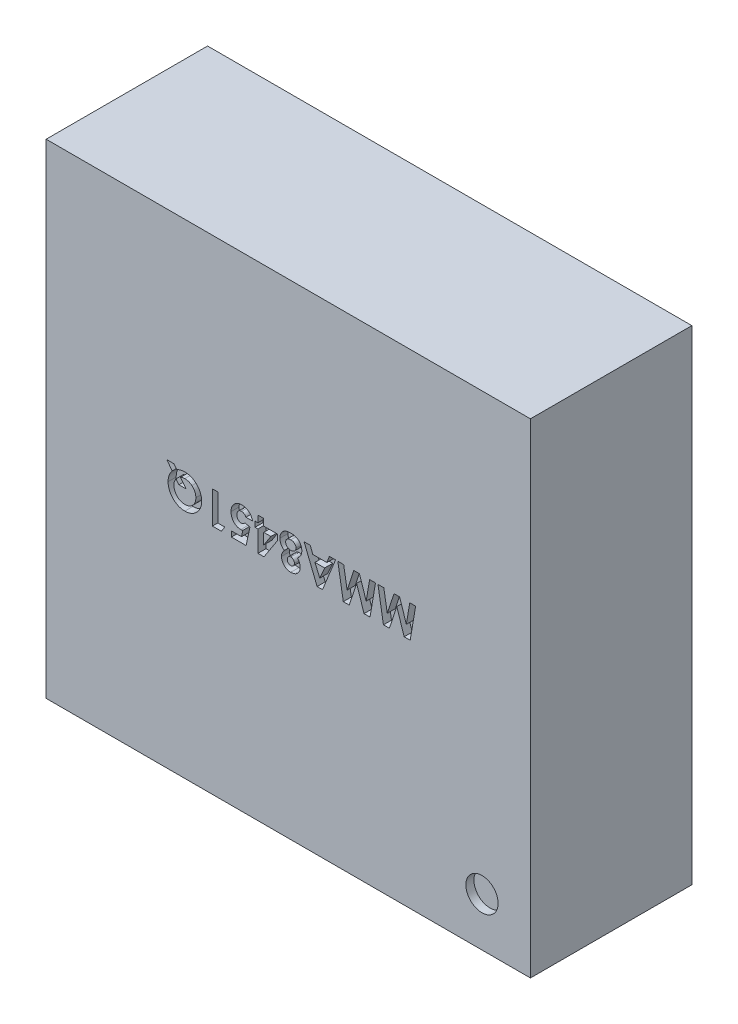
from build123d import *

# Parameters (mm, degrees)
SCHIZZO1_W                   = 3
SCHIZZO1_H                   = 3
ESTRUSIONE_ESTRUSIONE1_DEPTH = 1
TAGLIO_ESTRUSIONE1_DEPTH     = 0.05
SCHIZZO3_R                   = 0.1
TAGLIO_ESTRUSIONE2_DEPTH     = 0.05


with BuildPart() as part:
    # Schizzo1 → Estrusione-Estrusione1 (new body)
    with BuildSketch(Plane.XY):
        with Locations((1.5, 1.5)):
            Rectangle(SCHIZZO1_W, SCHIZZO1_H)
    extrude(amount=ESTRUSIONE_ESTRUSIONE1_DEPTH)

    # Schizzo2 → Taglio-Estrusione1 (cut)
    with BuildSketch(Plane.XY.offset(1)):
        Polygon((2.255120111, 1.439408505), (2.217860496, 1.439408505), (2.172227483, 1.57891171), (2.126273957, 1.439408505), (2.089374919, 1.439408505), (2.055560816, 1.639408505), (2.091898957, 1.639408505), (2.113253124, 1.51308639), (2.154839662, 1.639408505), (2.189855688, 1.639408505), (2.231201842, 1.51308639), (2.252515944, 1.639408505), (2.288894149, 1.639408505), align=None)
        Polygon((2.006402162, 1.439408505), (1.969142547, 1.439408505), (1.923509534, 1.57891171), (1.877556008, 1.439408505), (1.84065697, 1.439408505), (1.806842867, 1.639408505), (1.843181008, 1.639408505), (1.864535175, 1.51308639), (1.906121714, 1.639408505), (1.941137739, 1.639408505), (1.982483893, 1.51308639), (2.003797996, 1.639408505), (2.040176201, 1.639408505), align=None)
        Polygon((1.711931008, 1.439408505), (1.678637739, 1.439408505), (1.597868508, 1.639408505), (1.636209855, 1.639408505), (1.651754726, 1.598382864), (1.738894149, 1.598382864), (1.754439021, 1.639408505), (1.792740303, 1.639408505), align=None)
        Polygon((1.695304406, 1.493054338), (1.725272355, 1.562485428), (1.665336457, 1.562485428), align=None, mode=Mode.SUBTRACT)
        with BuildLine():
            add(Edge.make_bspline(
                [(1.475272355, 1.531716197), (1.473174734, 1.533214414), (1.469022685, 1.53618), (1.463553194, 1.541491573), (1.45881142, 1.547397544), (1.45486563, 1.553878723), (1.45171337, 1.560815484), (1.449547066, 1.568114497), (1.448098465, 1.575662829), (1.447945723, 1.580801283), (1.447868508, 1.58339889)],
                knots=[0, 0, 0, 0, 7.724e-06, 1.529e-05, 2.2786e-05, 3.0392e-05, 3.7995e-05, 4.5574e-05, 5.3189e-05, 6.0974e-05, 6.0974e-05, 6.0974e-05, 6.0974e-05], degree=3))
            add(Edge.make_bspline(
                [(1.447868508, 1.58339889), (1.447963328, 1.586211217), (1.448151391, 1.591789107), (1.449818242, 1.599968088), (1.452480363, 1.607818284), (1.456152804, 1.615246932), (1.460736074, 1.622049379), (1.466046988, 1.628119642), (1.472164822, 1.633189867), (1.477814874, 1.636679063), (1.482712005, 1.638942737), (1.48663211, 1.64048813), (1.490839032, 1.641706274), (1.495262585, 1.642754008), (1.499948926, 1.643539533), (1.504851919, 1.644157897), (1.51001753, 1.644457776), (1.513533286, 1.644509951), (1.515336457, 1.64453671)],
                knots=[0, 0, 0, 0, 8.43e-06, 1.6719e-05, 2.4929e-05, 3.3243e-05, 4.1499e-05, 4.9474e-05, 5.7353e-05, 6.5248e-05, 6.9317e-05, 7.3528e-05, 7.7876e-05, 8.2443e-05, 8.7159e-05, 9.2124e-05, 9.7262e-05, 0.000102672, 0.000102672, 0.000102672, 0.000102672], degree=3))
            add(Edge.make_bspline(
                [(1.515336457, 1.64453671), (1.517259849, 1.644510473), (1.521015855, 1.644459236), (1.52649937, 1.644153208), (1.531669796, 1.643578114), (1.536550559, 1.642854562), (1.541096901, 1.641780111), (1.545369218, 1.640612022), (1.549321298, 1.63916093), (1.554152226, 1.636922846), (1.559751981, 1.633575715), (1.565728375, 1.628571639), (1.571053363, 1.622704405), (1.575513142, 1.615931994), (1.579229331, 1.608542297), (1.581881464, 1.600572463), (1.583478894, 1.592130125), (1.583669122, 1.586343939), (1.583765944, 1.58339889)],
                knots=[0, 0, 0, 0, 5.77e-06, 1.1269e-05, 1.6467e-05, 2.1374e-05, 2.6059e-05, 3.0473e-05, 3.4655e-05, 3.8671e-05, 4.6435e-05, 5.4145e-05, 6.1974e-05, 7.0119e-05, 7.8397e-05, 8.672e-05, 9.5238e-05, 0.000104068, 0.000104068, 0.000104068, 0.000104068], degree=3))
            add(Edge.make_bspline(
                [(1.583765944, 1.58339889), (1.583699882, 1.580828655), (1.583569986, 1.57577486), (1.582218931, 1.568398584), (1.580159054, 1.561343636), (1.577148533, 1.554674957), (1.573368853, 1.548311853), (1.568660948, 1.542384881), (1.56318548, 1.536748952), (1.559018628, 1.533421609), (1.556882931, 1.531716197)],
                knots=[0, 0, 0, 0, 7.703e-06, 1.5146e-05, 2.2422e-05, 2.9703e-05, 3.7034e-05, 4.4568e-05, 5.2359e-05, 6.0551e-05, 6.0551e-05, 6.0551e-05, 6.0551e-05], degree=3))
            add(Edge.make_bspline(
                [(1.556882931, 1.531716197), (1.558207018, 1.530189886), (1.560813745, 1.527185037), (1.564178132, 1.522344969), (1.567049191, 1.517364535), (1.569365917, 1.512214275), (1.571228576, 1.506953564), (1.572568417, 1.501550026), (1.57333037, 1.495987468), (1.573449408, 1.492228587), (1.573509534, 1.490329979)],
                knots=[0, 0, 0, 0, 6.058e-06, 1.1927e-05, 1.7651e-05, 2.3281e-05, 2.8844e-05, 3.4373e-05, 3.9954e-05, 4.565e-05, 4.565e-05, 4.565e-05, 4.565e-05], degree=3))
            add(Edge.make_bspline(
                [(1.573509534, 1.490329979), (1.573430438, 1.487759632), (1.573274386, 1.482688437), (1.571866729, 1.475265663), (1.569581685, 1.468187924), (1.566358072, 1.461548301), (1.562391141, 1.455409429), (1.557588715, 1.449982648), (1.552092392, 1.44524061), (1.545869846, 1.441281529), (1.539030809, 1.438153041), (1.531650405, 1.435904192), (1.523762687, 1.434508086), (1.51832046, 1.434357384), (1.515536778, 1.4342803)],
                knots=[0, 0, 0, 0, 7.705e-06, 1.5202e-05, 2.2575e-05, 2.9958e-05, 3.7281e-05, 4.4434e-05, 5.1622e-05, 5.899e-05, 6.6484e-05, 7.4113e-05, 8.2083e-05, 9.0428e-05, 9.0428e-05, 9.0428e-05, 9.0428e-05], degree=3))
            add(Edge.make_bspline(
                [(1.515536778, 1.4342803), (1.512793171, 1.434357286), (1.507443713, 1.434507392), (1.499682449, 1.435899564), (1.492438044, 1.43819607), (1.485720458, 1.441365902), (1.479584485, 1.445371003), (1.474185721, 1.45025658), (1.469402872, 1.45582552), (1.465390595, 1.46210962), (1.462161873, 1.468880232), (1.459803283, 1.475994075), (1.458420065, 1.48337197), (1.458223694, 1.488374552), (1.458124919, 1.490890877)],
                knots=[0, 0, 0, 0, 8.225e-06, 1.6037e-05, 2.3563e-05, 3.0965e-05, 3.8254e-05, 4.5461e-05, 5.2735e-05, 6.0215e-05, 6.7759e-05, 7.5183e-05, 8.2641e-05, 9.0188e-05, 9.0188e-05, 9.0188e-05, 9.0188e-05], degree=3))
            add(Edge.make_bspline(
                [(1.458124919, 1.490890877), (1.458172799, 1.492669127), (1.458266761, 1.496158809), (1.458958948, 1.50130085), (1.460131298, 1.506231724), (1.461743636, 1.511089958), (1.464078698, 1.51594002), (1.467063659, 1.521016113), (1.47085941, 1.526328266), (1.473755045, 1.529863657), (1.475272355, 1.531716197)],
                knots=[0, 0, 0, 0, 5.334e-06, 1.0467e-05, 1.553e-05, 2.0522e-05, 2.5791e-05, 3.1646e-05, 3.8171e-05, 4.5354e-05, 4.5354e-05, 4.5354e-05, 4.5354e-05], degree=3))
        make_face()
        with BuildLine():
            add(Edge.make_bspline(
                [(1.516418188, 1.470177736), (1.517895864, 1.47025031), (1.52078309, 1.470392112), (1.524883649, 1.471627748), (1.528576876, 1.473652577), (1.531764766, 1.476464288), (1.534354839, 1.479913015), (1.536291315, 1.483843989), (1.537428727, 1.488237035), (1.537549786, 1.491311546), (1.537612098, 1.492894082)],
                knots=[0, 0, 0, 0, 4.425e-06, 8.646e-06, 1.2717e-05, 1.6976e-05, 2.1295e-05, 2.5577e-05, 3.0047e-05, 3.4788e-05, 3.4788e-05, 3.4788e-05, 3.4788e-05], degree=3))
            add(Edge.make_bspline(
                [(1.537612098, 1.492894082), (1.53753441, 1.494489875), (1.537382716, 1.497605816), (1.536216072, 1.50209271), (1.534154258, 1.506133121), (1.531388651, 1.509670903), (1.528113977, 1.512658782), (1.524314136, 1.514781206), (1.520155226, 1.516138621), (1.517230115, 1.516266375), (1.515737098, 1.516331582)],
                knots=[0, 0, 0, 0, 4.784e-06, 9.342e-06, 1.3786e-05, 1.8297e-05, 2.2752e-05, 2.6986e-05, 3.1269e-05, 3.5734e-05, 3.5734e-05, 3.5734e-05, 3.5734e-05], degree=3))
            add(Edge.make_bspline(
                [(1.515737098, 1.516331582), (1.514219142, 1.516262437), (1.511261878, 1.51612773), (1.507039909, 1.51484466), (1.503276016, 1.512697421), (1.499990418, 1.509817109), (1.497329683, 1.506249698), (1.495376159, 1.50214471), (1.494250994, 1.497520122), (1.494100432, 1.494289133), (1.494022355, 1.492613633)],
                knots=[0, 0, 0, 0, 4.545e-06, 8.854e-06, 1.3088e-05, 1.746e-05, 2.1867e-05, 2.6348e-05, 3.1012e-05, 3.6036e-05, 3.6036e-05, 3.6036e-05, 3.6036e-05], degree=3))
            add(Edge.make_bspline(
                [(1.494022355, 1.492613633), (1.494096604, 1.491030212), (1.494240362, 1.48796449), (1.495427272, 1.48360019), (1.49739041, 1.479703045), (1.50008166, 1.47632135), (1.503430738, 1.473580733), (1.507326271, 1.471567677), (1.511731127, 1.470399531), (1.514822001, 1.470253268), (1.516418188, 1.470177736)],
                knots=[0, 0, 0, 0, 4.745e-06, 9.186e-06, 1.345e-05, 1.7755e-05, 2.2054e-05, 2.6337e-05, 3.0817e-05, 3.5601e-05, 3.5601e-05, 3.5601e-05, 3.5601e-05], degree=3))
        make_face(mode=Mode.SUBTRACT)
        with BuildLine():
            add(Edge.make_bspline(
                [(1.515256329, 1.552229018), (1.516379613, 1.552247247), (1.518593593, 1.552283178), (1.521845958, 1.552713148), (1.524979833, 1.553323553), (1.527940309, 1.554274553), (1.530805813, 1.555385499), (1.533504014, 1.556836245), (1.536081141, 1.558521478), (1.538481586, 1.560441776), (1.540651704, 1.562547435), (1.542607692, 1.564744086), (1.544206477, 1.567087888), (1.545537873, 1.569501093), (1.54660766, 1.572002781), (1.54731487, 1.574634162), (1.547770214, 1.57736019), (1.547835551, 1.57921705), (1.547868508, 1.580153697)],
                knots=[0, 0, 0, 0, 3.368e-06, 6.637e-06, 9.827e-06, 1.2932e-05, 1.5953e-05, 1.9035e-05, 2.2102e-05, 2.5181e-05, 2.8241e-05, 3.1165e-05, 3.3988e-05, 3.6732e-05, 3.9425e-05, 4.2127e-05, 4.4887e-05, 4.7696e-05, 4.7696e-05, 4.7696e-05, 4.7696e-05], degree=3))
            add(Edge.make_bspline(
                [(1.547868508, 1.580153697), (1.547852726, 1.58113049), (1.547821425, 1.583067837), (1.547351937, 1.585896213), (1.546670514, 1.588621442), (1.545731281, 1.591235811), (1.544400729, 1.593686399), (1.542892791, 1.596068868), (1.541070987, 1.598318537), (1.539002345, 1.600421009), (1.536720523, 1.602357107), (1.534225849, 1.604030708), (1.53157074, 1.60549792), (1.52871626, 1.606652678), (1.525691677, 1.60752897), (1.522515332, 1.608163523), (1.519167253, 1.608586565), (1.516873598, 1.608621403), (1.515697034, 1.608639274)],
                knots=[0, 0, 0, 0, 2.927e-06, 5.806e-06, 8.575e-06, 1.1351e-05, 1.4111e-05, 1.6922e-05, 1.9801e-05, 2.2775e-05, 2.5761e-05, 2.8761e-05, 3.1773e-05, 3.4846e-05, 3.7977e-05, 4.1207e-05, 4.4556e-05, 4.8084e-05, 4.8084e-05, 4.8084e-05, 4.8084e-05], degree=3))
            add(Edge.make_bspline(
                [(1.515697034, 1.608639274), (1.514507462, 1.608617712), (1.512189362, 1.608575694), (1.508800768, 1.608204331), (1.505595755, 1.607615089), (1.502578171, 1.606772325), (1.499736537, 1.60569275), (1.497109212, 1.604318523), (1.494635332, 1.602761642), (1.492397581, 1.600940892), (1.490358825, 1.598976398), (1.488627348, 1.596796392), (1.4870705, 1.594539608), (1.485899134, 1.592060406), (1.484895926, 1.589502771), (1.48429967, 1.586769368), (1.483804105, 1.583924159), (1.483778849, 1.581959032), (1.483765944, 1.580954979)],
                knots=[0, 0, 0, 0, 3.568e-06, 6.952e-06, 1.0213e-05, 1.3334e-05, 1.634e-05, 1.9314e-05, 2.2215e-05, 2.5093e-05, 2.7954e-05, 3.0689e-05, 3.3433e-05, 3.6157e-05, 3.8895e-05, 4.1655e-05, 4.4534e-05, 4.7541e-05, 4.7541e-05, 4.7541e-05, 4.7541e-05], degree=3))
            add(Edge.make_bspline(
                [(1.483765944, 1.580954979), (1.483802617, 1.579952357), (1.483874299, 1.577992577), (1.48426598, 1.575098239), (1.48500249, 1.572355374), (1.485960271, 1.569695569), (1.487252773, 1.567198164), (1.488780504, 1.564786695), (1.490647642, 1.562564595), (1.492711576, 1.560431579), (1.495031501, 1.558523013), (1.497520831, 1.556849098), (1.500113426, 1.555376067), (1.502892671, 1.554276149), (1.50577185, 1.553323107), (1.508826519, 1.55271318), (1.511998873, 1.552283079), (1.51415971, 1.552247218), (1.515256329, 1.552229018)],
                knots=[0, 0, 0, 0, 3.009e-06, 5.882e-06, 8.739e-06, 1.1515e-05, 1.4346e-05, 1.7157e-05, 2.0061e-05, 2.3035e-05, 2.6052e-05, 2.9052e-05, 3.2029e-05, 3.4975e-05, 3.8003e-05, 4.1115e-05, 4.4305e-05, 4.7593e-05, 4.7593e-05, 4.7593e-05, 4.7593e-05], degree=3))
        make_face(mode=Mode.SUBTRACT)
        Polygon((1.349390944, 1.4342803), (1.311971072, 1.4342803), (1.311971072, 1.565049531), (1.294022355, 1.565049531), (1.294022355, 1.598382864), (1.311971072, 1.598382864), (1.311971072, 1.639408505), (1.347868508, 1.639408505), (1.347868508, 1.598382864), (1.432483893, 1.598382864), (1.432483893, 1.562044723), align=None)
        Polygon((1.347868508, 1.565049531), (1.347868508, 1.49698062), (1.392139342, 1.565049531), align=None, mode=Mode.SUBTRACT)
        with BuildLine():
            Line((1.238934214, 1.439408505), (1.147868508, 1.439408505))
            Line((1.147868508, 1.439408505), (1.147868508, 1.472741838))
            Line((1.147868508, 1.472741838), (1.210488701, 1.472741838))
            Line((1.210488701, 1.472741838), (1.218301201, 1.510562351))
            add(Edge.make_bspline(
                [(1.218301201, 1.510562351), (1.217236789, 1.510264975), (1.215124903, 1.509674957), (1.211959482, 1.509102909), (1.208895836, 1.5087118), (1.206897425, 1.508663073), (1.205921393, 1.508639274)],
                knots=[0, 0, 0, 0, 3.314e-06, 6.575e-06, 9.641e-06, 1.2568e-05, 1.2568e-05, 1.2568e-05, 1.2568e-05], degree=3))
            add(Edge.make_bspline(
                [(1.205921393, 1.508639274), (1.203794745, 1.508688005), (1.199602654, 1.508784064), (1.193470156, 1.509695981), (1.187597927, 1.511132222), (1.182003937, 1.513180598), (1.176693649, 1.515846612), (1.171660628, 1.519071741), (1.166898696, 1.522861651), (1.162492444, 1.527218714), (1.158443796, 1.532002867), (1.154923727, 1.537177436), (1.151917369, 1.542668634), (1.149526216, 1.548510596), (1.147638914, 1.554666631), (1.146275107, 1.561140682), (1.14546862, 1.567940423), (1.14535987, 1.572579401), (1.145304406, 1.574945364)],
                knots=[0, 0, 0, 0, 6.376e-06, 1.2569e-05, 1.8555e-05, 2.4487e-05, 3.0399e-05, 3.6345e-05, 4.239e-05, 4.8622e-05, 5.4906e-05, 6.1163e-05, 6.7366e-05, 7.3653e-05, 8.0065e-05, 8.6658e-05, 9.3476e-05, 0.000100573, 0.000100573, 0.000100573, 0.000100573], degree=3))
            add(Edge.make_bspline(
                [(1.145304406, 1.574945364), (1.145371837, 1.577338305), (1.145504897, 1.582060277), (1.146382463, 1.589001199), (1.14790529, 1.59566107), (1.150083697, 1.601999569), (1.152832673, 1.60806312), (1.156150367, 1.613859098), (1.160160931, 1.619322951), (1.164700183, 1.624452027), (1.169652945, 1.629143954), (1.174939988, 1.633260533), (1.180471938, 1.6367859), (1.186327231, 1.639581932), (1.192416275, 1.641805239), (1.198760218, 1.643420277), (1.205386423, 1.644347197), (1.209884883, 1.644472845), (1.212171393, 1.64453671)],
                knots=[0, 0, 0, 0, 7.179e-06, 1.4166e-05, 2.0949e-05, 2.7639e-05, 3.4237e-05, 4.0896e-05, 4.7636e-05, 5.4533e-05, 6.142e-05, 6.8071e-05, 7.4607e-05, 8.1058e-05, 8.7497e-05, 9.4026e-05, 0.000100661, 0.00010752, 0.00010752, 0.00010752, 0.00010752], degree=3))
            add(Edge.make_bspline(
                [(1.212171393, 1.64453671), (1.214215744, 1.64448274), (1.218247632, 1.644376301), (1.224195886, 1.643767043), (1.229900717, 1.642557063), (1.235418372, 1.641037968), (1.240672564, 1.638943981), (1.245771565, 1.636537645), (1.250561877, 1.633516536), (1.25517959, 1.630188344), (1.259447184, 1.626408548), (1.263409521, 1.622324118), (1.266915877, 1.617858703), (1.270096885, 1.613099096), (1.272779713, 1.607956423), (1.275178005, 1.602523191), (1.277137269, 1.596738243), (1.27813215, 1.592728348), (1.278637739, 1.590690556)],
                knots=[0, 0, 0, 0, 6.135e-06, 1.2099e-05, 1.7905e-05, 2.3612e-05, 2.9244e-05, 3.4853e-05, 4.0501e-05, 4.6207e-05, 5.1913e-05, 5.758e-05, 6.3255e-05, 6.8922e-05, 7.4729e-05, 8.0631e-05, 8.6726e-05, 9.3023e-05, 9.3023e-05, 9.3023e-05, 9.3023e-05], degree=3))
            Line((1.278637739, 1.590690556), (1.237612098, 1.590690556))
            add(Edge.make_bspline(
                [(1.237612098, 1.590690556), (1.236862512, 1.592103204), (1.235405777, 1.594848523), (1.23262839, 1.598485024), (1.229540986, 1.601619264), (1.226061504, 1.60413403), (1.222374741, 1.60614966), (1.218472662, 1.607628598), (1.21435837, 1.608478282), (1.211547521, 1.608585255), (1.210128124, 1.608639274)],
                knots=[0, 0, 0, 0, 4.79e-06, 9.31e-06, 1.3672e-05, 1.7944e-05, 2.2139e-05, 2.6246e-05, 3.0419e-05, 3.4675e-05, 3.4675e-05, 3.4675e-05, 3.4675e-05], degree=3))
            add(Edge.make_bspline(
                [(1.210128124, 1.608639274), (1.209138857, 1.608602041), (1.207192457, 1.608528785), (1.20432461, 1.608141533), (1.201587643, 1.607407136), (1.198958742, 1.606393371), (1.196430103, 1.605112307), (1.194014464, 1.603538299), (1.191723933, 1.601681251), (1.189566143, 1.599571235), (1.187618527, 1.597212927), (1.18589575, 1.59469543), (1.184422019, 1.592020937), (1.18327649, 1.589159962), (1.182352082, 1.586144309), (1.181667295, 1.58297018), (1.181259023, 1.579630281), (1.181221158, 1.577350365), (1.181201842, 1.576187351)],
                knots=[0, 0, 0, 0, 2.969e-06, 5.842e-06, 8.66e-06, 1.145e-05, 1.4281e-05, 1.7148e-05, 2.0083e-05, 2.3114e-05, 2.6187e-05, 2.9243e-05, 3.2255e-05, 3.5327e-05, 3.847e-05, 4.1708e-05, 4.5057e-05, 4.8545e-05, 4.8545e-05, 4.8545e-05, 4.8545e-05], degree=3))
            add(Edge.make_bspline(
                [(1.181201842, 1.576187351), (1.181218051, 1.575050466), (1.181249625, 1.572835916), (1.181696268, 1.569601882), (1.182255946, 1.566505908), (1.183160687, 1.563576968), (1.184264532, 1.56078233), (1.185707628, 1.558186848), (1.187274045, 1.555671384), (1.189181997, 1.553419141), (1.191197645, 1.551333527), (1.193372732, 1.549519509), (1.195659081, 1.547992426), (1.198054301, 1.546744947), (1.200535966, 1.545711308), (1.203160191, 1.545068911), (1.205863102, 1.544578581), (1.207708538, 1.544550813), (1.208645752, 1.54453671)],
                knots=[0, 0, 0, 0, 3.408e-06, 6.638e-06, 9.781e-06, 1.2835e-05, 1.5819e-05, 1.8776e-05, 2.1732e-05, 2.4692e-05, 2.761e-05, 3.0426e-05, 3.3171e-05, 3.5841e-05, 3.852e-05, 4.1211e-05, 4.3932e-05, 4.6739e-05, 4.6739e-05, 4.6739e-05, 4.6739e-05], degree=3))
            add(Edge.make_bspline(
                [(1.208645752, 1.54453671), (1.209663966, 1.544574282), (1.211704687, 1.544649584), (1.214726161, 1.545294498), (1.217737846, 1.546249037), (1.220700561, 1.547674327), (1.22364217, 1.549503055), (1.226567735, 1.551712478), (1.229465423, 1.55433791), (1.231296324, 1.556301388), (1.232243508, 1.557317159)],
                knots=[0, 0, 0, 0, 3.051e-06, 6.116e-06, 9.233e-06, 1.2512e-05, 1.5948e-05, 1.961e-05, 2.3496e-05, 2.7661e-05, 2.7661e-05, 2.7661e-05, 2.7661e-05], degree=3))
            Line((1.232243508, 1.557317159), (1.262451842, 1.550386069))
            Line((1.262451842, 1.550386069), (1.238934214, 1.439408505))
        make_face()
        Polygon((1.085408572, 1.439408505), (1.02991979, 1.439408505), (1.02991979, 1.639408505), (1.065817226, 1.639408505), (1.065817226, 1.472741838), (1.106842867, 1.472741838), align=None)
        with BuildLine():
            Line((0.781201842, 1.610922928), (0.747267547, 1.65479312))
            Line((0.747267547, 1.65479312), (0.791939021, 1.65479312))
            Line((0.791939021, 1.65479312), (0.809527162, 1.632076774))
            add(Edge.make_bspline(
                [(0.809527162, 1.632076774), (0.811369467, 1.633079926), (0.815045385, 1.635081499), (0.820809711, 1.637577443), (0.826680744, 1.639767068), (0.832743559, 1.641482857), (0.838939946, 1.642833391), (0.845302012, 1.643864546), (0.851825204, 1.644408251), (0.856227671, 1.644493677), (0.858445431, 1.64453671)],
                knots=[0, 0, 0, 0, 6.29e-06, 1.2551e-05, 1.8825e-05, 2.5077e-05, 3.1434e-05, 3.7843e-05, 4.4398e-05, 5.1051e-05, 5.1051e-05, 5.1051e-05, 5.1051e-05], degree=3))
            add(Edge.make_bspline(
                [(0.858445431, 1.64453671), (0.862136107, 1.644447859), (0.869373067, 1.644273633), (0.879992319, 1.642798121), (0.890126038, 1.640357835), (0.899797441, 1.636940773), (0.908982356, 1.632547832), (0.917694756, 1.627189523), (0.925893966, 1.620813779), (0.933520449, 1.613549256), (0.940478231, 1.6056605), (0.946564114, 1.597286376), (0.951720315, 1.588555198), (0.955969205, 1.579456002), (0.959219484, 1.569940806), (0.961527049, 1.560062873), (0.962980612, 1.549814734), (0.963161375, 1.542858886), (0.963253124, 1.539328377)],
                knots=[0, 0, 0, 0, 1.1068e-05, 2.1703e-05, 3.2091e-05, 4.2292e-05, 5.2416e-05, 6.2579e-05, 7.2917e-05, 8.3516e-05, 9.4133e-05, 0.000104431, 0.000114525, 0.000124509, 0.000134505, 0.000144631, 0.000154903, 0.000165491, 0.000165491, 0.000165491, 0.000165491], degree=3))
            add(Edge.make_bspline(
                [(0.963253124, 1.539328377), (0.963222206, 1.536962777), (0.963160761, 1.532261531), (0.962436619, 1.525292754), (0.961363089, 1.518469841), (0.959891782, 1.511780646), (0.957919247, 1.505251846), (0.955504799, 1.49887516), (0.952690027, 1.492635457), (0.949463414, 1.486564863), (0.945817407, 1.48075115), (0.941884002, 1.475178369), (0.937593763, 1.46993681), (0.932980396, 1.464993438), (0.928025533, 1.460381352), (0.922776597, 1.45602879), (0.917160606, 1.452043334), (0.911278499, 1.448357624), (0.905199118, 1.445046317), (0.898939447, 1.442189071), (0.892585197, 1.439750584), (0.886116456, 1.437718091), (0.879517662, 1.436222512), (0.872834889, 1.435074632), (0.866016526, 1.434437613), (0.861438094, 1.434333078), (0.859126521, 1.4342803)],
                knots=[0, 0, 0, 0, 7.094e-06, 1.4099e-05, 2.0995e-05, 2.7809e-05, 3.4628e-05, 4.1436e-05, 4.825e-05, 5.5151e-05, 6.2043e-05, 6.8824e-05, 7.5601e-05, 8.2347e-05, 8.9094e-05, 9.5896e-05, 0.000102788, 0.000109736, 0.00011671, 0.00012354, 0.000130363, 0.000137117, 0.000143862, 0.000150646, 0.000157447, 0.000164383, 0.000164383, 0.000164383, 0.000164383], degree=3))
            add(Edge.make_bspline(
                [(0.859126521, 1.4342803), (0.855635672, 1.434369085), (0.848756948, 1.434544037), (0.838638174, 1.436039432), (0.828881046, 1.438423028), (0.819521837, 1.441861567), (0.810524481, 1.446213098), (0.801899627, 1.451534337), (0.793689389, 1.457862259), (0.785922756, 1.465020411), (0.778843541, 1.472896799), (0.772602398, 1.481283863), (0.767321971, 1.490099817), (0.763003064, 1.499332076), (0.759658907, 1.509000994), (0.757324516, 1.519101274), (0.755821238, 1.529614539), (0.755648568, 1.536772422), (0.755560816, 1.540410108)],
                knots=[0, 0, 0, 0, 1.0468e-05, 2.0627e-05, 3.0616e-05, 4.0553e-05, 5.0479e-05, 6.0553e-05, 7.0898e-05, 8.153e-05, 9.2197e-05, 0.000102622, 0.000112846, 0.000122973, 0.000133147, 0.000143477, 0.000154033, 0.000164941, 0.000164941, 0.000164941, 0.000164941], degree=3))
            add(Edge.make_bspline(
                [(0.755560816, 1.540410108), (0.755635236, 1.543765857), (0.7557819, 1.550379211), (0.757019715, 1.560111858), (0.759010264, 1.569487107), (0.761834716, 1.578510759), (0.76544314, 1.587194735), (0.769882172, 1.59551471), (0.775083013, 1.603507081), (0.77914968, 1.608435767), (0.781201842, 1.610922928)],
                knots=[0, 0, 0, 0, 1.0064e-05, 1.9834e-05, 2.9381e-05, 3.8784e-05, 4.8159e-05, 5.755e-05, 6.704e-05, 7.6707e-05, 7.6707e-05, 7.6707e-05, 7.6707e-05], degree=3))
        make_face()
        with BuildLine():
            add(Edge.make_bspline(
                [(0.804759534, 1.580394082), (0.80369098, 1.578862106), (0.801578491, 1.575833451), (0.79890551, 1.571029591), (0.79660939, 1.56613213), (0.794710588, 1.561115369), (0.793266171, 1.555950558), (0.792239513, 1.550671414), (0.791559641, 1.54527552), (0.791492225, 1.541640798), (0.791458252, 1.539809146)],
                knots=[0, 0, 0, 0, 5.6e-06, 1.1072e-05, 1.6467e-05, 2.1817e-05, 2.7144e-05, 3.2534e-05, 3.7941e-05, 4.3433e-05, 4.3433e-05, 4.3433e-05, 4.3433e-05], degree=3))
            add(Edge.make_bspline(
                [(0.791458252, 1.539809146), (0.791521493, 1.537429121), (0.791645973, 1.532744405), (0.792580576, 1.525857684), (0.794147182, 1.519258177), (0.79632844, 1.51292757), (0.799091483, 1.506847131), (0.802521431, 1.501049382), (0.806593984, 1.495548939), (0.811217659, 1.490383864), (0.816236234, 1.485648275), (0.82161657, 1.48153196), (0.827237454, 1.478011528), (0.833162349, 1.47517736), (0.839306482, 1.472891512), (0.845739399, 1.471357971), (0.852404065, 1.470352283), (0.856945966, 1.470236425), (0.859246714, 1.470177736)],
                knots=[0, 0, 0, 0, 7.139e-06, 1.4051e-05, 2.0805e-05, 2.7457e-05, 3.4108e-05, 4.0807e-05, 4.7627e-05, 5.4607e-05, 6.158e-05, 6.8295e-05, 7.4899e-05, 8.1439e-05, 8.7966e-05, 9.4526e-05, 0.000101245, 0.000108144, 0.000108144, 0.000108144, 0.000108144], degree=3))
            add(Edge.make_bspline(
                [(0.859246714, 1.470177736), (0.861613707, 1.470239664), (0.866272458, 1.470361552), (0.873111908, 1.47131435), (0.879672377, 1.472808855), (0.885919417, 1.475003146), (0.891871811, 1.477768076), (0.897529773, 1.481160418), (0.902863105, 1.485200456), (0.907891554, 1.48976495), (0.912419615, 1.494850811), (0.916488778, 1.500245141), (0.919779391, 1.506073686), (0.922608701, 1.512145526), (0.92469862, 1.518613929), (0.926289865, 1.525373989), (0.927156564, 1.532495081), (0.927288368, 1.53733639), (0.927355688, 1.539809146)],
                knots=[0, 0, 0, 0, 7.099e-06, 1.3972e-05, 2.0677e-05, 2.7253e-05, 3.3795e-05, 4.0336e-05, 4.7003e-05, 5.3838e-05, 6.0675e-05, 6.7406e-05, 7.4065e-05, 8.0716e-05, 8.7469e-05, 9.4418e-05, 0.000101524, 0.000108943, 0.000108943, 0.000108943, 0.000108943], degree=3))
            add(Edge.make_bspline(
                [(0.927355688, 1.539809146), (0.927274278, 1.54255046), (0.927114728, 1.547922982), (0.925996805, 1.555761399), (0.924068443, 1.563171806), (0.921329195, 1.570113638), (0.917870063, 1.576646567), (0.91357182, 1.582674577), (0.908553232, 1.588309014), (0.904681392, 1.591589612), (0.902716265, 1.593254659)],
                knots=[0, 0, 0, 0, 8.223e-06, 1.6116e-05, 2.3695e-05, 3.1143e-05, 3.8455e-05, 4.5814e-05, 5.3304e-05, 6.1023e-05, 6.1023e-05, 6.1023e-05, 6.1023e-05], degree=3))
            add(Edge.make_bspline(
                [(0.902716265, 1.593254659), (0.90110823, 1.594487018), (0.897919362, 1.596930891), (0.892812, 1.600026673), (0.887584707, 1.60270125), (0.882183026, 1.604878861), (0.876603405, 1.606561722), (0.870865654, 1.60775556), (0.864969122, 1.608507047), (0.860985091, 1.608594805), (0.858966265, 1.608639274)],
                knots=[0, 0, 0, 0, 6.074e-06, 1.2045e-05, 1.7886e-05, 2.3674e-05, 2.9492e-05, 3.5346e-05, 4.1239e-05, 4.7294e-05, 4.7294e-05, 4.7294e-05, 4.7294e-05], degree=3))
            add(Edge.make_bspline(
                [(0.858966265, 1.608639274), (0.856651052, 1.608559946), (0.85205809, 1.608402574), (0.845272884, 1.607209528), (0.838699951, 1.605222343), (0.834559936, 1.603282097), (0.832483893, 1.602309146)],
                knots=[0, 0, 0, 0, 6.943e-06, 1.3773e-05, 2.0604e-05, 2.7474e-05, 2.7474e-05, 2.7474e-05, 2.7474e-05], degree=3))
            Line((0.832483893, 1.602309146), (0.86721947, 1.557357223))
            Line((0.86721947, 1.557357223), (0.822547996, 1.557357223))
            Line((0.822547996, 1.557357223), (0.804759534, 1.580394082))
        make_face(mode=Mode.SUBTRACT)
    extrude(amount=-TAGLIO_ESTRUSIONE1_DEPTH, mode=Mode.SUBTRACT)

    # Schizzo3 → Taglio-Estrusione2 (cut)
    with BuildSketch(Plane.XY.offset(1)):
        with Locations((2.7, 0.3)):
            Circle(SCHIZZO3_R)
    extrude(amount=-TAGLIO_ESTRUSIONE2_DEPTH, mode=Mode.SUBTRACT)


solid = part.part
